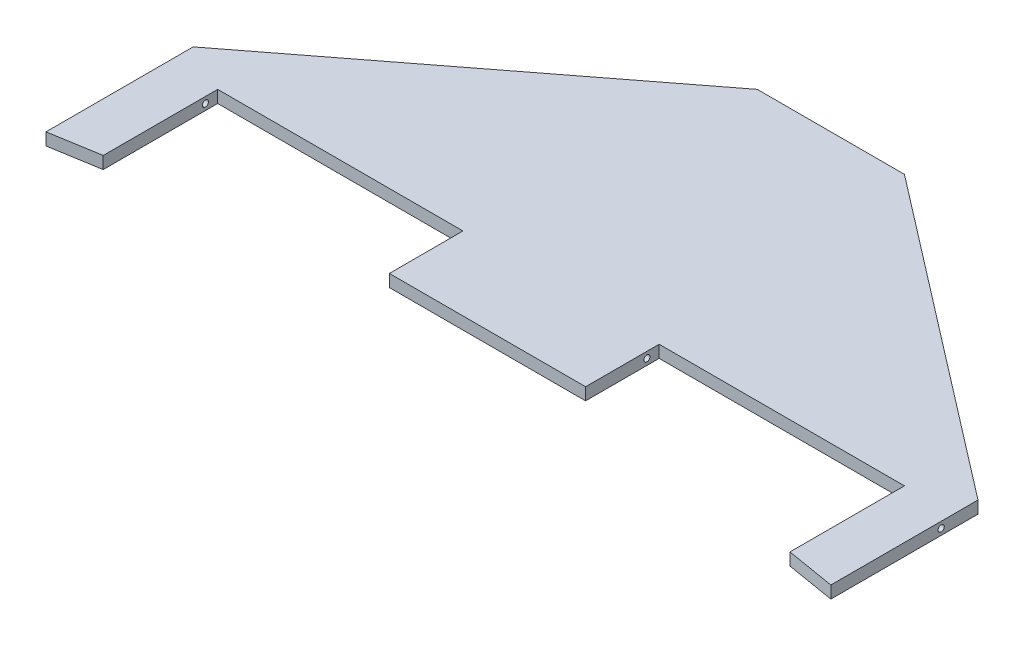
from build123d import *

# Parameters (mm, degrees)
EXTRUDE1_DEPTH     = 3.175
CUT_EXTRUDE1_START = -127
SKETCH3_R          = 0.79375
CUT_EXTRUDE1_DEPTH = 203.2


with BuildPart() as part:
    # Sketch1 → Extrude1 (new body)
    with BuildSketch(Plane(origin=(0, 0, 0), x_dir=(1, 0, 0), z_dir=(0, 1, 0))):
        Polygon((25.4, 0), (-25.4, 0), (-25.4, 19.05), (-88.9, 19.05), (-88.9, -10.583333333), (-101.6, -12.7), (-101.6, 25.4), (-19.05, 88.9), (19.05, 88.9), (101.6, 25.4), (101.6, -12.7), (88.9, -10.583333333), (88.9, 19.05), (25.4, 19.05), align=None)
    extrude(amount=EXTRUDE1_DEPTH)

    # Sketch3 → Cut-Extrude1 (cut)
    with BuildSketch(Plane(origin=(25.4, 0, 0), x_dir=(0, 0, -1), z_dir=(1, 0, 0)).offset(CUT_EXTRUDE1_START)):
        with Locations((15.875, 1.5875)):
            Circle(SKETCH3_R)
    extrude(amount=CUT_EXTRUDE1_DEPTH, mode=Mode.SUBTRACT)


solid = part.part
